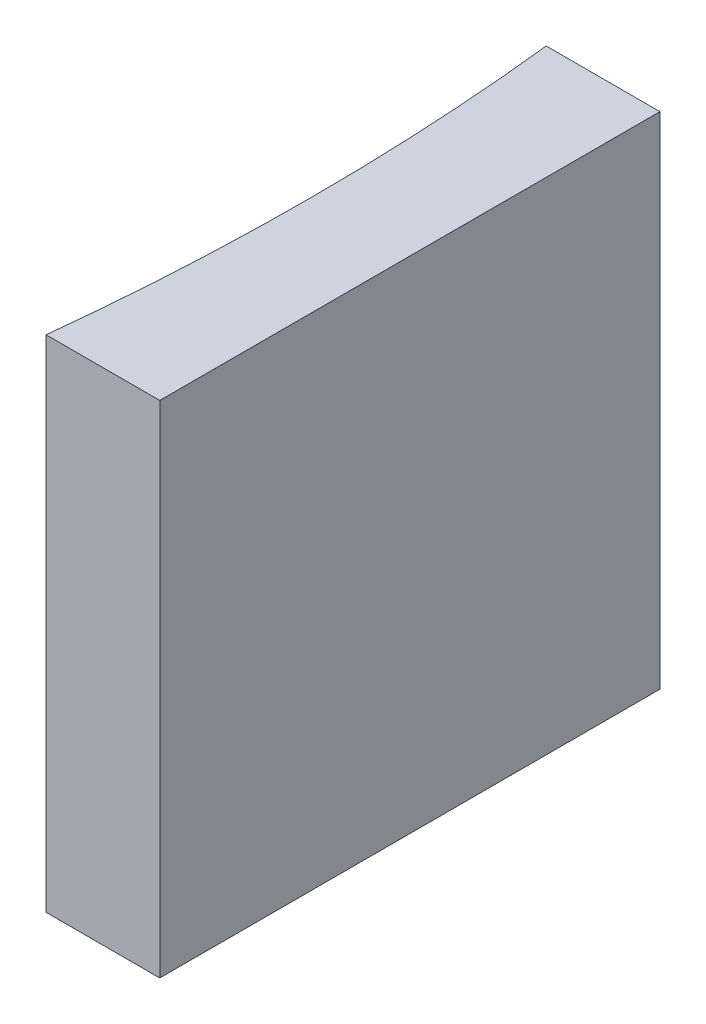
from build123d import *

# Parameters (mm, degrees)
EXTRUDE_1_DEPTH = 10


with BuildPart() as part:
    # 草图1 → 凸台-拉伸1 (new body)
    with BuildSketch(Plane(origin=(0, 0, 0), x_dir=(1, 0, 0), z_dir=(0, 1, 0))):
        with BuildLine():
            Line((0, 0), (0, -10))
            Line((0, -10), (-2.273443526, -10))
            ThreePointArc((-2.273443526, -10), (-2, -5), (-2.273443526, 0))
            Line((-2.273443526, 0), (0, 0))
        make_face()
    extrude(amount=EXTRUDE_1_DEPTH)


solid = part.part
